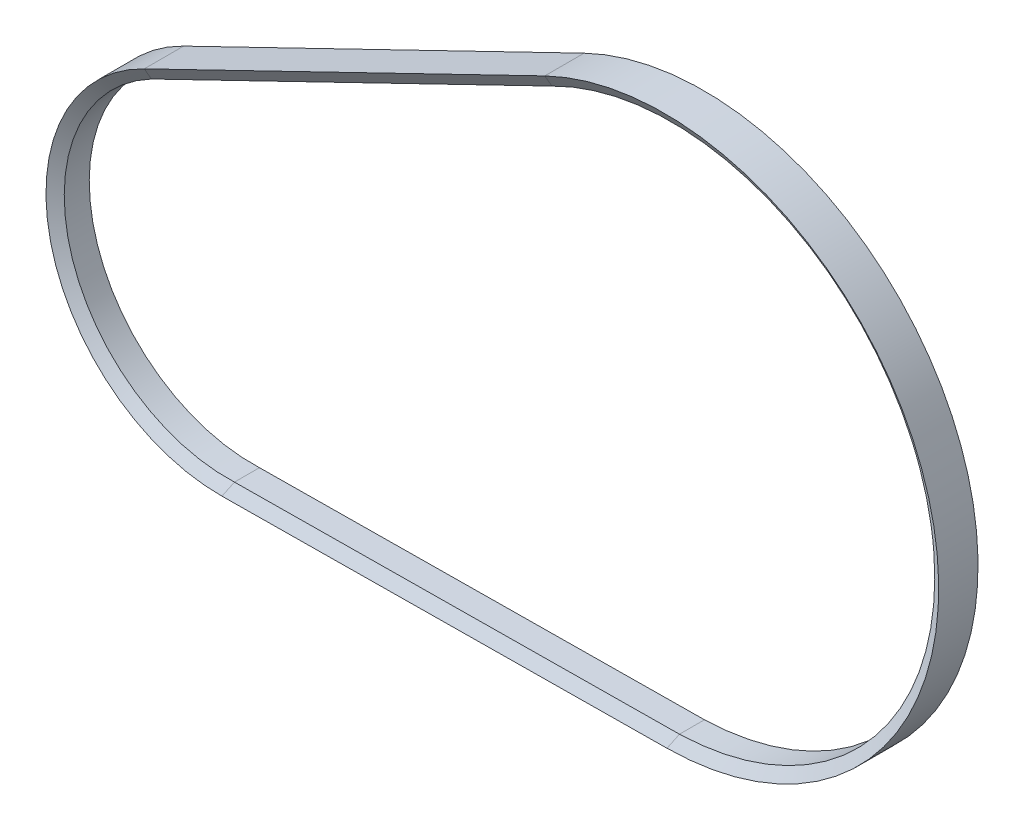
from build123d import *


with BuildPart() as part:
    # Sweep1: sweep along a path in Sketch1
    with BuildLine(Plane.XY) as sweep1_path:
        Line((24.020712033, -129.927195225), (-190.815645031, -131.952384486))
        ThreePointArc((-190.815645031, -131.952384486), (-273.555159883, -67.006536582), (-228.321889895, 27.955254493))
        Line((-228.321889895, 27.955254493), (-34.990242075, 121.665636306))
        ThreePointArc((-34.990242075, 121.665636306), (151.70340481, 32.737615478), (24.020712033, -129.927195225))
    # Sketch2 → Sweep1 (sweep)
    with BuildSketch(Plane(origin=(-34.990242075, 0, 0), x_dir=(0, 0, -1), z_dir=(1, 0, 0))):
        Polygon((6.04, 115.665636306), (-6.03, 115.665636306), (-9.494101615, 121.665636306), (9.504101615, 121.665636306), align=None)
    sweep(path=sweep1_path.line)


solid = part.part
